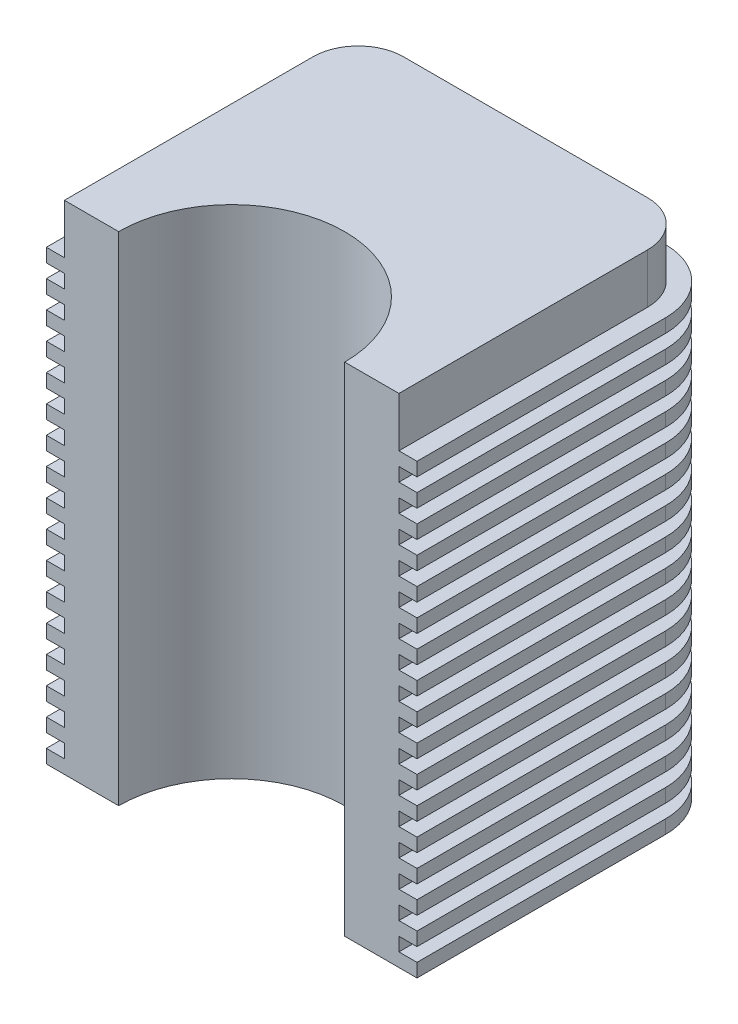
from build123d import *

# Parameters (mm, degrees)
BOSS_EXTRUDE1_DEPTH = 110
BOSS_EXTRUDE2_DEPTH = 3
LPATTERN1_COUNT     = 17
LPATTERN1_PITCH     = 6


with BuildPart() as part:
    # Sketch1 → Boss-Extrude1 (new body)
    with BuildSketch(Plane(origin=(0, 0, 0), x_dir=(1, 0, 0), z_dir=(0, 1, 0))):
        with BuildLine():
            Line((25, 0), (37, 0))
            Line((37, 0), (37, 55))
            ThreePointArc((37, 55), (34.071067812, 62.071067812), (27, 65))
            Line((27, 65), (-27, 65))
            ThreePointArc((-27, 65), (-34.071067812, 62.071067812), (-37, 55))
            Line((-37, 55), (-37, 0))
            Line((-37, 0), (-25, 0))
            ThreePointArc((-25, 0), (0, 25), (25, 0))
        make_face()
    extrude(amount=BOSS_EXTRUDE1_DEPTH)

    # Sketch2 → Boss-Extrude2 (add)
    with BuildSketch(Plane.XZ):
        with BuildLine():
            Line((-27, -69), (27, -69))
            ThreePointArc((27, -69), (36.899494937, -64.899494937), (41, -55))
            Line((41, -55), (41, 0))
            Line((41, 0), (37, 0))
            Line((37, 0), (37, -55))
            ThreePointArc((37, -55), (34.071067812, -62.071067812), (27, -65))
            Line((27, -65), (-27, -65))
            ThreePointArc((-27, -65), (-34.071067812, -62.071067812), (-37, -55))
            Line((-37, -55), (-37, 0))
            Line((-37, 0), (-41, 0))
            Line((-41, 0), (-41, -55))
            ThreePointArc((-41, -55), (-36.899494937, -64.899494937), (-27, -69))
        make_face()
    boss_extrude2 = extrude(amount=-BOSS_EXTRUDE2_DEPTH)

    # LPattern1: Boss-Extrude2 ×17
    with Locations(*[(0, i * LPATTERN1_PITCH, 0) for i in range(1, LPATTERN1_COUNT)]):
        add(boss_extrude2)


solid = part.part
